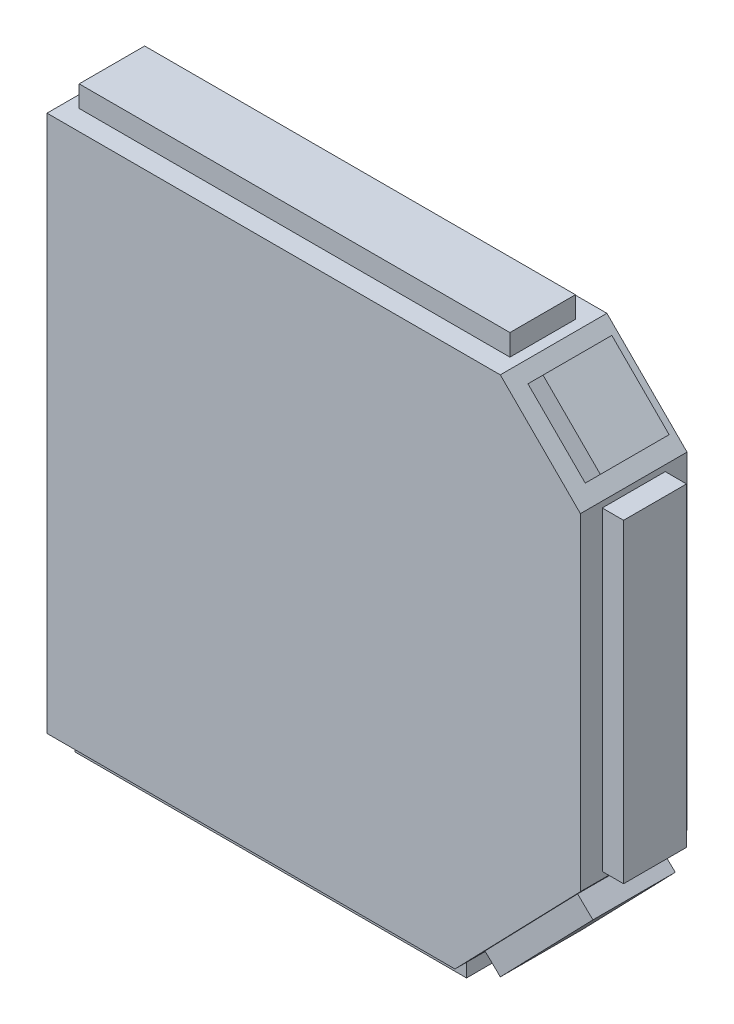
from build123d import *

# Parameters (mm, degrees)
BOSS_EXTRUDE1_DEPTH = 25.4
SKETCH2_W           = 14.241894923
SKETCH2_H           = 50
CUT_EXTRUDE1_DEPTH  = 25.4
SKETCH3_W           = 15
SKETCH3_H           = 75
CUT_EXTRUDE2_DEPTH  = 114.391883
SKETCH4_W           = 93.269947502
SKETCH4_H           = 16.780785534
CUT_EXTRUDE3_DEPTH  = 38.1
SKETCH5_W           = 102.635967335
SKETCH5_H           = 15.610033055
CUT_EXTRUDE4_DEPTH  = 101.6
SKETCH6_W           = 16.390534708
SKETCH6_H           = 19.316430399
CUT_EXTRUDE5_DEPTH  = 25.4
SKETCH7_W           = 19.62251785
SKETCH7_H           = 31.734588897
CUT_EXTRUDE6_DEPTH  = 25.4
SKETCH4_2_W         = 93.269947502
SKETCH4_2_H         = 16.780785534
BOSS_EXTRUDE2_DEPTH = 5.08
SKETCH5_2_W         = 102.635967335
SKETCH5_2_H         = 15.610033055
BOSS_EXTRUDE4_DEPTH = 5.08
SKETCH7_2_W         = 19.62251785
SKETCH7_2_H         = 31.734588897
BOSS_EXTRUDE5_DEPTH = 5.08
SKETCH6_2_W         = 16.390534708
SKETCH6_2_H         = 19.316430399
BOSS_EXTRUDE6_DEPTH = 5.08
SKETCH3_2_W         = 15
SKETCH3_2_H         = 75
BOSS_EXTRUDE7_DEPTH = 5.08
SKETCH2_3_W         = 14.241894923
SKETCH2_3_H         = 50
BOSS_EXTRUDE8_DEPTH = 5.08


with BuildPart() as part:
    # Sketch1 → Boss-Extrude1 (new body)
    with BuildSketch(Plane.XY):
        Polygon((0, 0), (108, 0), (127.091883092, -19.091883092), (127.091883092, -97.091883092), (97.193068366, -128), (0, -128), align=None)
    extrude(amount=BOSS_EXTRUDE1_DEPTH)

    # Sketch2 → Cut-Extrude1 (cut)
    with BuildSketch(Plane.ZY):
        with Locations((13.208639104, -101.003494845)):
            Rectangle(SKETCH2_W, SKETCH2_H)
    extrude(amount=-CUT_EXTRUDE1_DEPTH, mode=Mode.SUBTRACT)

    # Sketch3 → Cut-Extrude2 (cut)
    with BuildSketch(Plane(origin=(127.091883092, 0, 0), x_dir=(0, 0, -1), z_dir=(1, 0, 0))):
        with Locations((-12.7, -58.023490523)):
            Rectangle(SKETCH3_W, SKETCH3_H)
    extrude(amount=-CUT_EXTRUDE2_DEPTH, mode=Mode.SUBTRACT)

    # Sketch4 → Cut-Extrude3 (cut)
    with BuildSketch(Plane(origin=(0, -128, 0), x_dir=(-1, 0, 0), z_dir=(0, -1, 0))):
        with Locations((-48.716410144, -12.40731188)):
            Rectangle(SKETCH4_W, SKETCH4_H)
    extrude(amount=-CUT_EXTRUDE3_DEPTH, mode=Mode.SUBTRACT)

    # Sketch5 → Cut-Extrude4 (cut)
    with BuildSketch(Plane(origin=(0, 0, 0), x_dir=(1, 0, 0), z_dir=(0, 1, 0))):
        with Locations((54.179921714, -12.797562707)):
            Rectangle(SKETCH5_W, SKETCH5_H)
    extrude(amount=-CUT_EXTRUDE4_DEPTH, mode=Mode.SUBTRACT)

    # Sketch6 → Cut-Extrude5 (cut)
    with BuildSketch(Plane(origin=(54, 54, 0), x_dir=(0, 0, -1), z_dir=(0.707106781, 0.707106781, 0))):
        with Locations((-13.187813533, -89.661925571)):
            Rectangle(SKETCH6_W, SKETCH6_H)
    extrude(amount=-CUT_EXTRUDE5_DEPTH, mode=Mode.SUBTRACT)

    # Sketch7 → Cut-Extrude6 (cut)
    with BuildSketch(Plane(origin=(114.174090835, -110.445744673, 0), x_dir=(0, 0, -1), z_dir=(0.71874467, -0.695274118, 0))):
        with Locations((-12.635731111, -2.507429786)):
            Rectangle(SKETCH7_W, SKETCH7_H)
    extrude(amount=-CUT_EXTRUDE6_DEPTH, mode=Mode.SUBTRACT)


with BuildPart() as body_2:
    # Sketch4_2 → Boss-Extrude2 (new body)
    with BuildSketch(Plane(origin=(0, -128, 0), x_dir=(-1, 0, 0), z_dir=(0, -1, 0))):
        with Locations((-48.716410144, -12.40731188)):
            Rectangle(SKETCH4_2_W, SKETCH4_2_H)
    extrude(amount=BOSS_EXTRUDE2_DEPTH)


with BuildPart() as body_3:
    # Sketch5_2 → Boss-Extrude4 (new body)
    with BuildSketch(Plane(origin=(0, 0, 0), x_dir=(1, 0, 0), z_dir=(0, 1, 0))):
        with Locations((54.179921714, -12.797562707)):
            Rectangle(SKETCH5_2_W, SKETCH5_2_H)
    extrude(amount=BOSS_EXTRUDE4_DEPTH)


with BuildPart() as body_4:
    # Sketch7_2 → Boss-Extrude5 (new body)
    with BuildSketch(Plane(origin=(114.174090835, -110.445744673, 0), x_dir=(0, 0, -1), z_dir=(0.71874467, -0.695274118, 0))):
        with Locations((-12.635731111, -2.507429786)):
            Rectangle(SKETCH7_2_W, SKETCH7_2_H)
    extrude(amount=BOSS_EXTRUDE5_DEPTH)


with BuildPart() as body_5:
    # Sketch6_2 → Boss-Extrude6 (new body)
    with BuildSketch(Plane(origin=(54, 54, 0), x_dir=(0, 0, -1), z_dir=(0.707106781, 0.707106781, 0))):
        with Locations((-13.187813533, -89.661925571)):
            Rectangle(SKETCH6_2_W, SKETCH6_2_H)
    extrude(amount=BOSS_EXTRUDE6_DEPTH)


with BuildPart() as body_6:
    # Sketch3_2 → Boss-Extrude7 (new body)
    with BuildSketch(Plane(origin=(127.091883092, 0, 0), x_dir=(0, 0, -1), z_dir=(1, 0, 0))):
        with Locations((-12.7, -58.023490523)):
            Rectangle(SKETCH3_2_W, SKETCH3_2_H)
    extrude(amount=BOSS_EXTRUDE7_DEPTH)


with BuildPart() as body_7:
    # Sketch2_3 → Boss-Extrude8 (new body)
    with BuildSketch(Plane.ZY):
        with Locations((13.208639104, -101.003494845)):
            Rectangle(SKETCH2_3_W, SKETCH2_3_H)
    extrude(amount=BOSS_EXTRUDE8_DEPTH)


solid = Compound([part.part, body_2.part, body_3.part, body_4.part, body_5.part, body_6.part, body_7.part])
